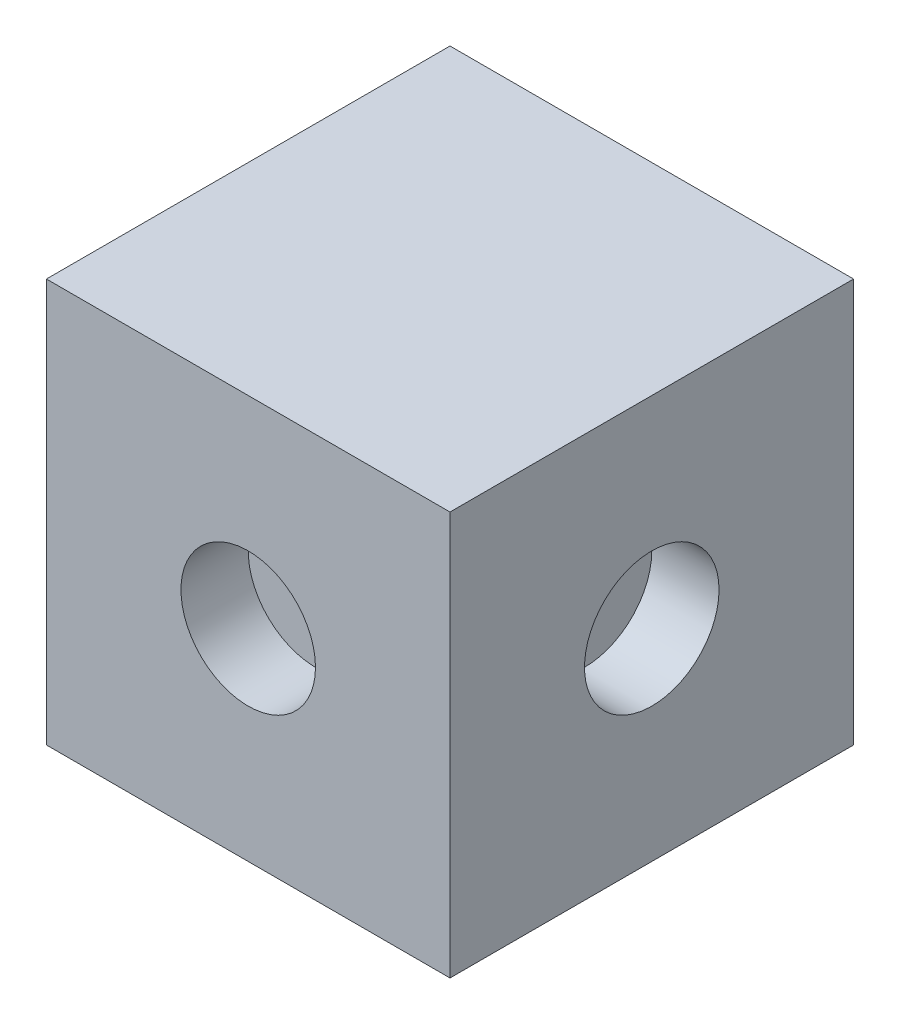
from build123d import *

# Parameters (mm, degrees)
SKETCH_1_W               = 12
SKETCH_1_H               = 12
EXTRUDE_1_DEPTH          = 12
SKETCH_2_R               = 2
CUT_EXTRUDE_1_DEPTH      = 2
PATTERN_CIRCULAR_1_COUNT = 4


with BuildPart() as part:
    # 草圖1 → 填料-伸長1 (new body)
    with BuildSketch(Plane(origin=(0, 0, 0), x_dir=(1, 0, 0), z_dir=(0, 1, 0))):
        Rectangle(SKETCH_1_W, SKETCH_1_H)
    extrude(amount=EXTRUDE_1_DEPTH)

    # 草圖2 → 除料-伸長1 (cut)
    with BuildSketch(Plane.XY.offset(6)):
        with Locations((0, 6)):
            Circle(SKETCH_2_R)
    cut_extrude_1 = extrude(amount=-CUT_EXTRUDE_1_DEPTH, mode=Mode.SUBTRACT)

    # 環狀複製排列1: 除料-伸長1 ×4 about axis
    pattern_circular_1_axis = Axis((0, 12.6, 0), (0, -1, 0))
    for i in range(1, PATTERN_CIRCULAR_1_COUNT):
        add(cut_extrude_1.rotate(pattern_circular_1_axis, i * 360 / PATTERN_CIRCULAR_1_COUNT), mode=Mode.SUBTRACT)


solid = part.part
